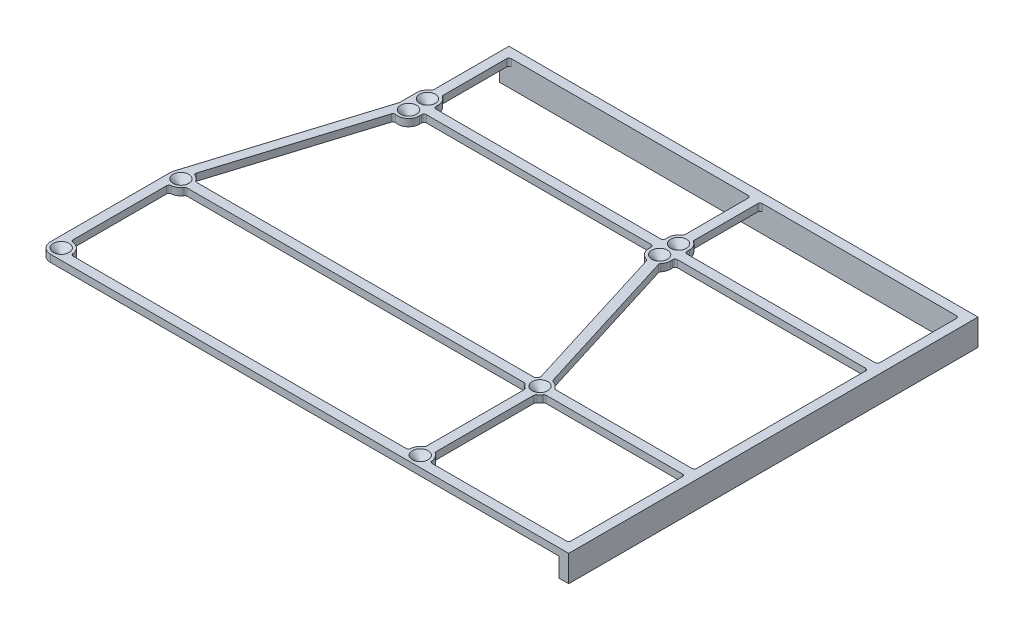
from build123d import *

# Parameters (mm, degrees)
SKETCH1_R           = 0.5
BOSS_EXTRUDE1_DEPTH = 3
BOSS_EXTRUDE2_DEPTH = 8
CHAMFER1_SIZE       = 2.8
FILLET1_R           = 1


with BuildPart() as part:
    # Sketch1 → Boss-Extrude1 (new body)
    with BuildSketch(Plane(origin=(0, 0, 0), x_dir=(1, 0, 0), z_dir=(0, 1, 0))):
        with BuildLine():
            Line((-191.955, 0), (-191.955, 4))
            Line((-191.955, 4), (4, 4))
            Line((4, 4), (4, -167))
            Line((4, -167), (0, -167))
            Line((0, -167), (-212.5, -167))
            ThreePointArc((-212.5, -167), (-215.681980515, -165.681980515), (-217, -162.5))
            Line((-217, -162.5), (-217, -112.5))
            ThreePointArc((-217, -112.5), (-216.949028292, -111.824613255), (-216.797267886, -111.164526783))
            Line((-216.797267886, -111.164526783), (-194.455, -39.271875472))
            Line((-194.455, -39.271875472), (-194.455, -32.045))
            ThreePointArc((-194.455, -32.045), (-193.779264635, -29.673291755), (-191.955, -28.013871126))
            Line((-191.955, -28.013871126), (-191.955, 0))
        make_face()
        with Locations((-62.5, -162.5)):
            Circle(SKETCH1_R, mode=Mode.SUBTRACT)
        with Locations((-62.5, -112.5)):
            Circle(SKETCH1_R, mode=Mode.SUBTRACT)
        with Locations((-212.5, -112.5)):
            Circle(SKETCH1_R, mode=Mode.SUBTRACT)
        with Locations((-212.5, -162.5)):
            Circle(SKETCH1_R, mode=Mode.SUBTRACT)
        with Locations((-189.955, -32.045)):
            Circle(SKETCH1_R, mode=Mode.SUBTRACT)
        with Locations((-189.955, -39.955)):
            Circle(SKETCH1_R, mode=Mode.SUBTRACT)
        with Locations((-85.045, -32.045)):
            Circle(SKETCH1_R, mode=Mode.SUBTRACT)
        with Locations((-85.045, -39.955)):
            Circle(SKETCH1_R, mode=Mode.SUBTRACT)
        with BuildLine():
            Line((0, 0), (-83.045, 0))
            Line((-83.045, 0), (-83.045, -28.013871126))
            ThreePointArc((-83.045, -28.013871126), (-81.220735365, -29.673291755), (-80.545, -32.045))
            Line((-80.545, -32.045), (-80.545, -34))
            Line((-80.545, -34), (0, -34))
            Line((0, -34), (0, 0))
        make_face(mode=Mode.SUBTRACT)
        with BuildLine():
            Line((0, -163), (0, -114.5))
            Line((0, -114.5), (-58.468871126, -114.5))
            ThreePointArc((-58.468871126, -114.5), (-59.318019485, -115.681980515), (-60.5, -116.531128874))
            Line((-60.5, -116.531128874), (-60.5, -158.468871126))
            ThreePointArc((-60.5, -158.468871126), (-58.549693914, -160.344754811), (-58.027864045, -163))
            Line((-58.027864045, -163), (0, -163))
        make_face(mode=Mode.SUBTRACT)
        with BuildLine():
            Line((-185.455, -32.045), (-185.455, -34))
            Line((-185.455, -34), (-89.545, -34))
            Line((-89.545, -34), (-89.545, -32.045))
            ThreePointArc((-89.545, -32.045), (-88.869264635, -29.673291755), (-87.045, -28.013871126))
            Line((-87.045, -28.013871126), (-87.045, 0))
            Line((-87.045, 0), (-187.955, 0))
            Line((-187.955, 0), (-187.955, -28.013871126))
            ThreePointArc((-187.955, -28.013871126), (-186.130735365, -29.673291755), (-185.455, -32.045))
        make_face(mode=Mode.SUBTRACT)
        with BuildLine():
            Line((-58.468871126, -110.5), (0, -110.5))
            Line((0, -110.5), (0, -38))
            Line((0, -38), (-80.545, -38))
            Line((-80.545, -38), (-80.545, -39.955))
            ThreePointArc((-80.545, -39.955), (-80.908092918, -41.725875431), (-81.938777685, -43.210976494))
            Line((-81.938777685, -43.210976494), (-61.786428638, -108.056936202))
            ThreePointArc((-61.786428638, -108.056936202), (-59.831632472, -108.876491377), (-58.468871126, -110.5))
        make_face(mode=Mode.SUBTRACT)
        with BuildLine():
            Line((-208.027864045, -163), (-66.972135955, -163))
            ThreePointArc((-66.972135955, -163), (-66.450306086, -160.344754811), (-64.5, -158.468871126))
            Line((-64.5, -158.468871126), (-64.5, -116.531128874))
            ThreePointArc((-64.5, -116.531128874), (-65.681980515, -115.681980515), (-66.531128874, -114.5))
            Line((-66.531128874, -114.5), (-208.468871126, -114.5))
            ThreePointArc((-208.468871126, -114.5), (-210.344754811, -116.450306086), (-213, -116.972135955))
            Line((-213, -116.972135955), (-213, -158.027864045))
            ThreePointArc((-213, -158.027864045), (-209.318019485, -159.318019485), (-208.027864045, -163))
        make_face(mode=Mode.SUBTRACT)
        with BuildLine():
            Line((-191.759678163, -44.077273248), (-211.650270256, -108.080954926))
            ThreePointArc((-211.650270256, -108.080954926), (-209.776281957, -108.917911221), (-208.468871126, -110.5))
            Line((-208.468871126, -110.5), (-66.531128874, -110.5))
            ThreePointArc((-66.531128874, -110.5), (-66.123508623, -109.831632472), (-65.606222315, -109.244023506))
            Line((-65.606222315, -109.244023506), (-85.758571362, -44.398063798))
            ThreePointArc((-85.758571362, -44.398063798), (-88.469986944, -42.873812162), (-89.545, -39.955))
            Line((-89.545, -39.955), (-89.545, -38))
            Line((-89.545, -38), (-185.455, -38))
            Line((-185.455, -38), (-185.455, -39.955))
            ThreePointArc((-185.455, -39.955), (-187.492384696, -43.721367728), (-191.759678163, -44.077273248))
        make_face(mode=Mode.SUBTRACT)
    extrude(amount=BOSS_EXTRUDE1_DEPTH)

    # Sketch2 → Boss-Extrude2 (add)
    with BuildSketch(Plane.XZ):
        Polygon((4, -4), (4, 167), (0, 167), (0, 0), (-191.955, 0), (-191.955, -4), align=None)
    extrude(amount=BOSS_EXTRUDE2_DEPTH)

    # Chamfer1
    chamfer1_edges = [part.edges().sort_by_distance(p)[0] for p in [
        (-63, 3, 112.5),
        (-213, 3, 112.5),
        (-213, 3, 162.5),
        (-63, 3, 162.5),
        (-190.455, 3, 32.045),
        (-190.455, 3, 39.955),
        (-85.545, 3, 32.045),
        (-85.545, 3, 39.955),
    ]]
    chamfer(chamfer1_edges, length=CHAMFER1_SIZE)

    # Fillet1
    fillet1_edges = [part.edges().sort_by_distance(p)[0] for p in [
        (-89.545, 1.5, 34),
        (-87.045, 1.5, 28.013871126),
        (-87.045, 1.5, 0),
        (-187.955, 1.5, 0),
        (-191.759678163, 1.5, 44.077273248),
        (-211.650270256, 1.5, 108.080954926),
        (-208.468871126, 1.5, 110.5),
        (-66.531128874, 1.5, 110.5),
        (-65.606222315, 1.5, 109.244023506),
        (-85.758571362, 1.5, 44.398063798),
        (-89.545, 1.5, 38),
        (-185.455, 1.5, 38),
        (-81.938777685, 1.5, 43.210976494),
        (-61.786428638, 1.5, 108.056936202),
        (-58.468871126, 1.5, 110.5),
        (0, 1.5, 110.5),
        (0, 1.5, 38),
        (-80.545, 1.5, 38),
        (-194.455, 1.5, 39.271875472),
        (-191.955, 1.5, 28.013871126),
        (0, 1.5, 34),
        (0, -2.5, 0),
        (-83.045, 1.5, 0),
        (-83.045, 1.5, 28.013871126),
        (-80.545, 1.5, 34),
        (-66.972135955, 1.5, 163),
        (-64.5, 1.5, 158.468871126),
        (-64.5, 1.5, 116.531128874),
        (-66.531128874, 1.5, 114.5),
        (-208.468871126, 1.5, 114.5),
        (-213, 1.5, 116.972135955),
        (-213, 1.5, 158.027864045),
        (-208.027864045, 1.5, 163),
        (-60.5, 1.5, 158.468871126),
        (-58.027864045, 1.5, 163),
        (0, 1.5, 163),
        (0, 1.5, 114.5),
        (-58.468871126, 1.5, 114.5),
        (-60.5, 1.5, 116.531128874),
        (-187.955, 1.5, 28.013871126),
        (-185.455, 1.5, 34),
    ]]
    fillet(fillet1_edges, radius=FILLET1_R)


solid = part.part
